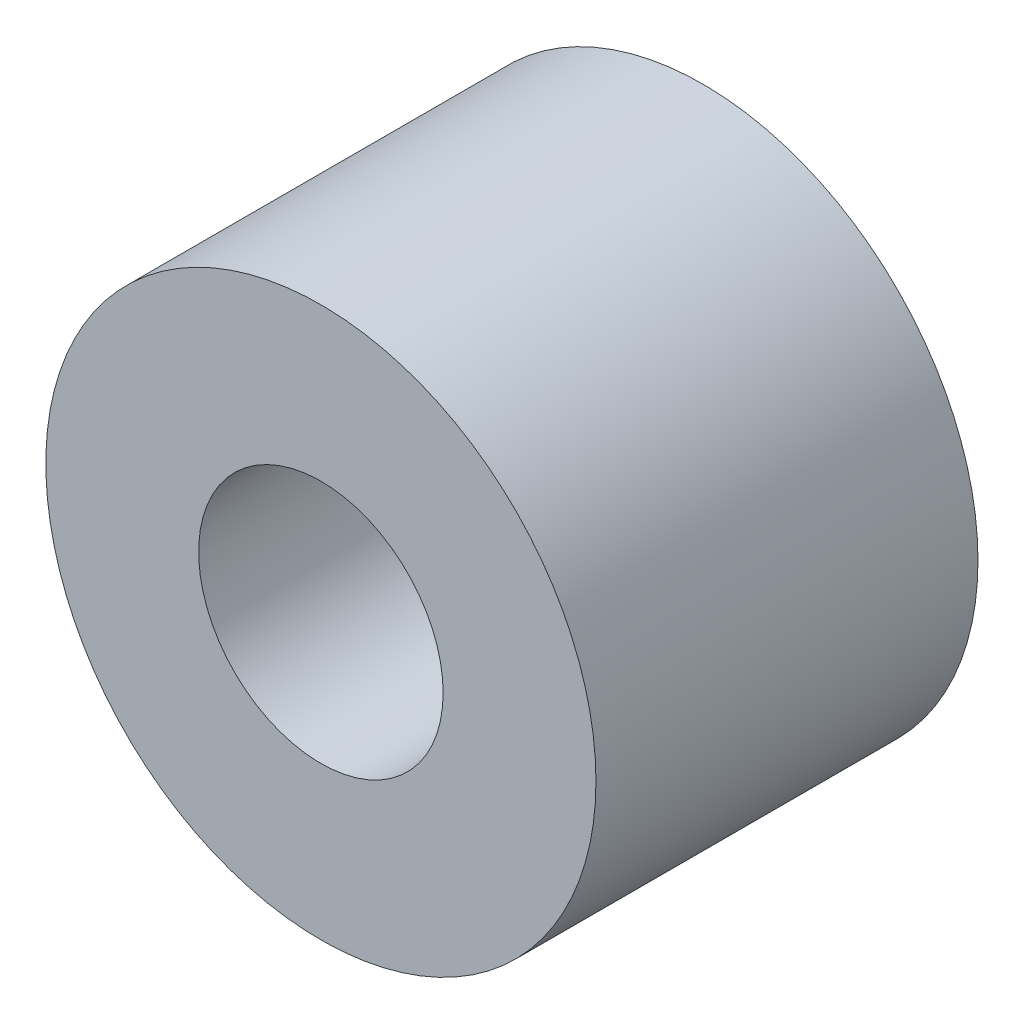
from build123d import *

# Parameters (mm, degrees)
SKETCH1_R           = 3.6
SKETCH1_R_2         = 1.6
BOSS_EXTRUDE1_DEPTH = 5


with BuildPart() as part:
    # Sketch1 → Boss-Extrude1 (new body)
    with BuildSketch(Plane.XY):
        Circle(SKETCH1_R)
        Circle(SKETCH1_R_2, mode=Mode.SUBTRACT)
    extrude(amount=BOSS_EXTRUDE1_DEPTH)


solid = part.part
